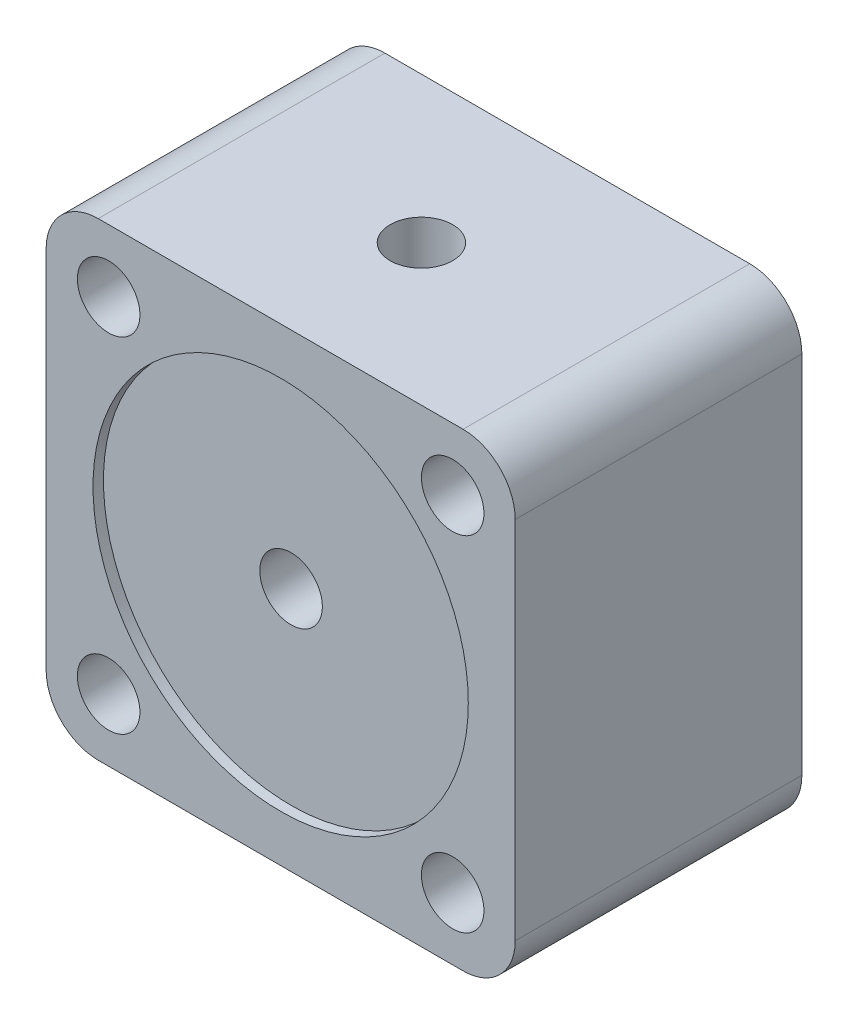
from build123d import *

# Parameters (mm, degrees)
SKETCH1_R           = 3
BOSS_EXTRUDE1_DEPTH = 27.5
SKETCH3_R           = 18
CUT_EXTRUDE1_DEPTH  = 1
SKETCH7_R           = 3
CUT_EXTRUDE2_DEPTH  = 20
SKETCH8_R           = 3
CUT_EXTRUDE3_DEPTH  = 16


with BuildPart() as part:
    # Sketch1 → Boss-Extrude1 (new body)
    with BuildSketch(Plane.XY):
        with BuildLine():
            Line((0, 40), (0, 5))
            ThreePointArc((0, 5), (-1.464466094, 1.464466094), (-5, 0))
            Line((-5, 0), (-40, 0))
            ThreePointArc((-40, 0), (-43.535533906, 1.464466094), (-45, 5))
            Line((-45, 5), (-45, 40))
            ThreePointArc((-45, 40), (-43.535533906, 43.535533906), (-40, 45))
            Line((-40, 45), (-5, 45))
            ThreePointArc((-5, 45), (-1.464466094, 43.535533906), (0, 40))
        make_face()
        with Locations((-6, 39)):
            Circle(SKETCH1_R, mode=Mode.SUBTRACT)
        with Locations((-6, 6)):
            Circle(SKETCH1_R, mode=Mode.SUBTRACT)
        with Locations((-39, 6)):
            Circle(SKETCH1_R, mode=Mode.SUBTRACT)
        with Locations((-39, 39)):
            Circle(SKETCH1_R, mode=Mode.SUBTRACT)
    extrude(amount=BOSS_EXTRUDE1_DEPTH)

    # Sketch3 → Cut-Extrude1 (cut)
    with BuildSketch(Plane.XY.offset(27.5)):
        with Locations((-22.5, 22.5)):
            Circle(SKETCH3_R)
    extrude(amount=-CUT_EXTRUDE1_DEPTH, mode=Mode.SUBTRACT)

    # Sketch7 → Cut-Extrude2 (cut)
    with BuildSketch(Plane(origin=(0, 45, 0), x_dir=(1, 0, 0), z_dir=(0, 1, 0))):
        with Locations((-22.5, -14)):
            Circle(SKETCH7_R)
    extrude(amount=-CUT_EXTRUDE2_DEPTH, mode=Mode.SUBTRACT)

    # Sketch8 → Cut-Extrude3 (cut)
    with BuildSketch(Plane.XY.offset(26.5)):
        with Locations((-22.5, 22.5)):
            Circle(SKETCH8_R)
    extrude(amount=-CUT_EXTRUDE3_DEPTH, mode=Mode.SUBTRACT)


solid = part.part
